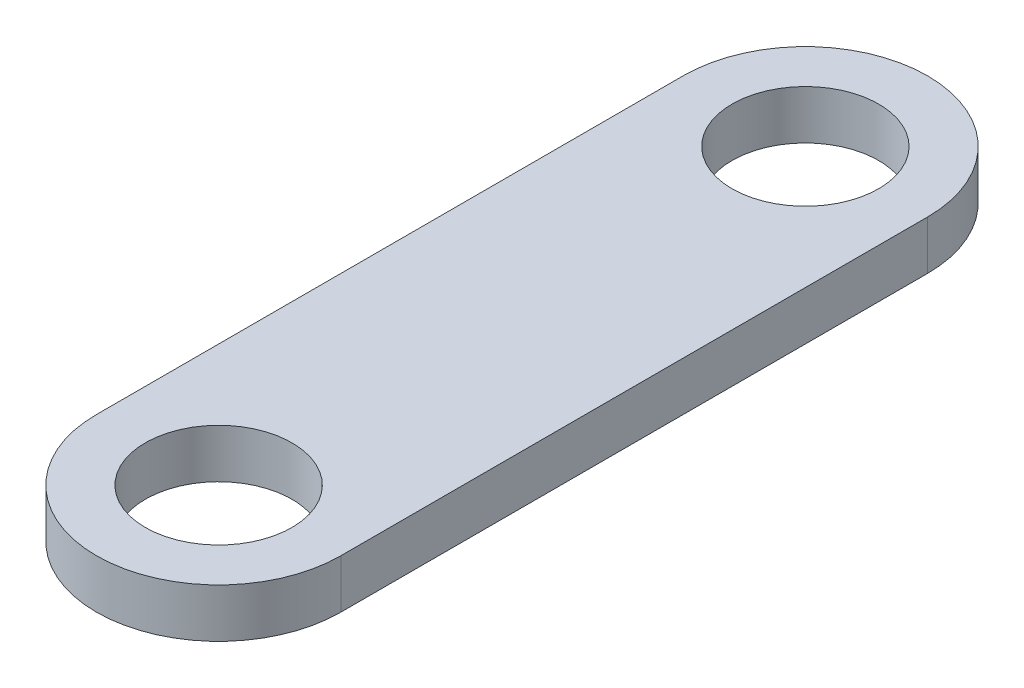
from build123d import *

# Parameters (mm, degrees)
SKETCH_1_R      = 1.5
EXTRUDE_1_DEPTH = 1


with BuildPart() as part:
    # 草图1 → 凸台-拉伸1 (new body)
    with BuildSketch(Plane(origin=(0, 0, 0), x_dir=(1, 0, 0), z_dir=(0, 1, 0))):
        with BuildLine():
            Line((-2.5, 0), (-2.5, -12))
            ThreePointArc((-2.5, -12), (0, -14.5), (2.5, -12))
            Line((2.5, -12), (2.5, 0))
            ThreePointArc((2.5, 0), (0, 2.5), (-2.5, 0))
        make_face()
        Circle(SKETCH_1_R, mode=Mode.SUBTRACT)
        with Locations((0, -12)):
            Circle(SKETCH_1_R, mode=Mode.SUBTRACT)
    extrude(amount=EXTRUDE_1_DEPTH)


solid = part.part
